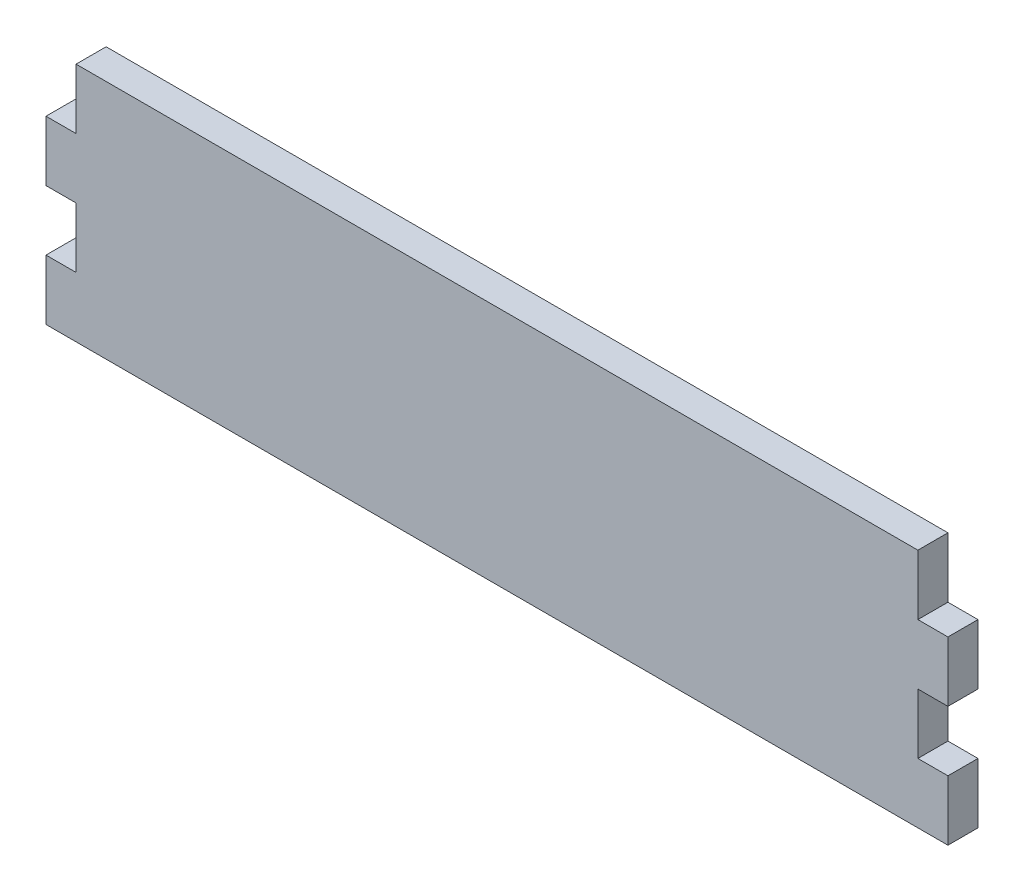
from build123d import *

# Parameters (mm, degrees)
SKETCH1_W               = 190.5
SKETCH1_H               = 50.8
BOSS_EXTRUDE1_DEPTH     = 6.35
SKETCH2_W               = 6.35
SKETCH2_H               = 12.7
CUT_EXTRUDE1_DEPTH      = 7.35
LPATTERN1_COUNT         = 2
LPATTERN1_PITCH         = 25.4
MIRROR1_COPY_1_SKETCH_W = 6.35
MIRROR1_COPY_1_SKETCH_H = 12.7
MIRROR1_COPY_1_DEPTH    = 7.35


with BuildPart() as part:
    # Sketch1 → Boss-Extrude1 (new body)
    with BuildSketch(Plane.XY):
        Rectangle(SKETCH1_W, SKETCH1_H)
    extrude(amount=BOSS_EXTRUDE1_DEPTH)

    # Sketch2 → Cut-Extrude1 (cut, through all)
    with BuildSketch(Plane.XY.offset(6.35)):
        with Locations((92.075, -6.35)):
            Rectangle(SKETCH2_W, SKETCH2_H)
    cut_extrude1 = extrude(amount=-CUT_EXTRUDE1_DEPTH, mode=Mode.SUBTRACT)

    # LPattern1: Cut-Extrude1 ×2
    with Locations(*[(0, i * LPATTERN1_PITCH, 0) for i in range(1, LPATTERN1_COUNT)]):
        add(cut_extrude1, mode=Mode.SUBTRACT)

    # Mirror1: Cut-Extrude1 across plane
    add(cut_extrude1.mirror(Plane(origin=(0, 0, 0), x_dir=(0, 0, 1), z_dir=(1, 0, 0))), mode=Mode.SUBTRACT)

    # Mirror1 copy 1 sketch → Mirror1 copy 1 (cut, through all)
    with BuildSketch(Plane(origin=(0, 25.4, 6.35), x_dir=(-1, 0, 0), z_dir=(0, 0, 1))):
        with Locations((92.075, 6.35)):
            Rectangle(MIRROR1_COPY_1_SKETCH_W, MIRROR1_COPY_1_SKETCH_H)
    extrude(amount=-MIRROR1_COPY_1_DEPTH, mode=Mode.SUBTRACT)


solid = part.part
